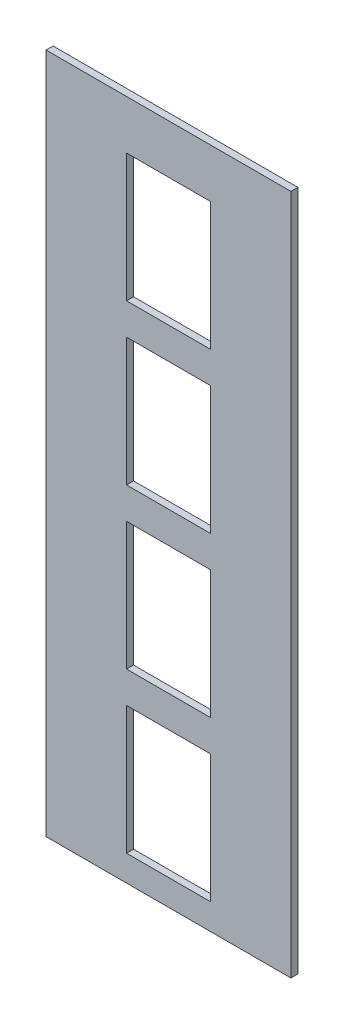
from build123d import *

# Parameters (mm, degrees)
SKETCH1_W           = 240
SKETCH1_H           = 974
SKETCH1_W_2         = 120
SKETCH1_H_2         = 183
BOSS_EXTRUDE1_DEPTH = 10
MOVE_FACE1_BY       = 5
MOVE_FACE2_BY       = 105


with BuildPart() as part:
    # Sketch1 → Boss-Extrude1 (new body)
    with BuildSketch(Plane.XY):
        with Locations((120, 487)):
            Rectangle(SKETCH1_W, SKETCH1_H)
        with Locations((170, 128.5)):
            Rectangle(SKETCH1_W_2, SKETCH1_H_2, mode=Mode.SUBTRACT)
        with Locations((170, 356.5)):
            Rectangle(SKETCH1_W_2, SKETCH1_H_2, mode=Mode.SUBTRACT)
        with Locations((170, 584.5)):
            Rectangle(SKETCH1_W_2, SKETCH1_H_2, mode=Mode.SUBTRACT)
        with Locations((170, 812.5)):
            Rectangle(SKETCH1_W_2, SKETCH1_H_2, mode=Mode.SUBTRACT)
    extrude(amount=BOSS_EXTRUDE1_DEPTH)

    # Move Face1: a face moved outward by 5.0
    extrude(part.faces().sort_by_distance((0, 487, 5))[0], amount=MOVE_FACE1_BY, dir=(-1, 0, 0))

    # Move Face2: a face moved outward by 105.0
    extrude(part.faces().sort_by_distance((240, 487, 5))[0], amount=MOVE_FACE2_BY, dir=(1, 0, 0))


solid = part.part
